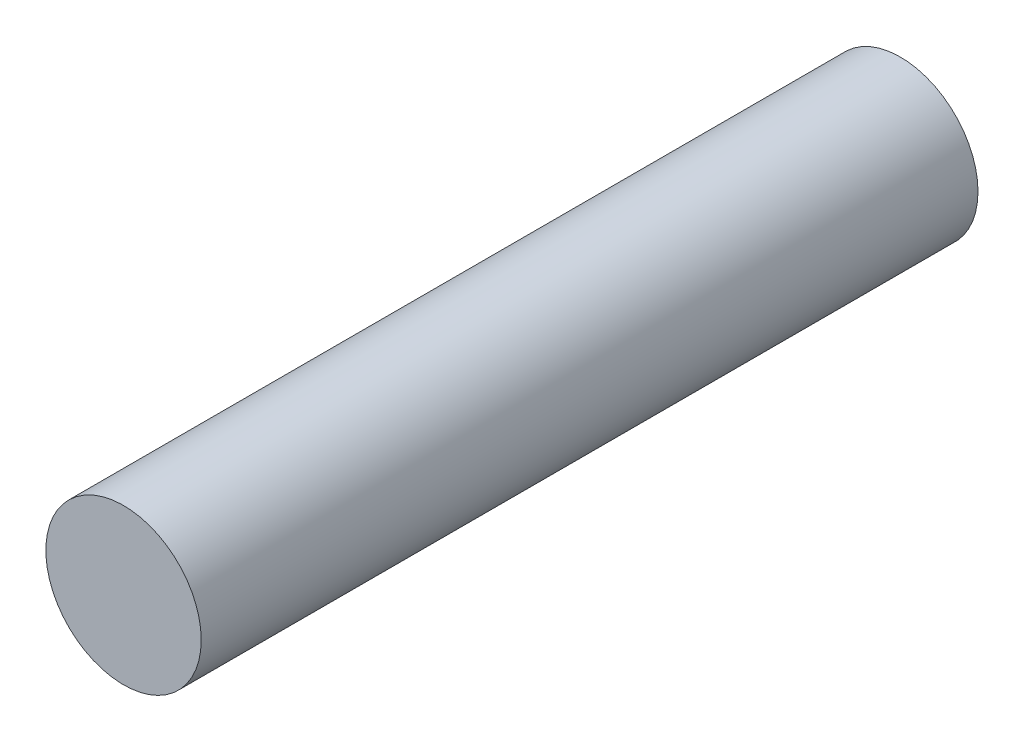
from build123d import *

# Parameters (mm, degrees)
SKETCH_1_R      = 1
EXTRUDE_1_DEPTH = 10


with BuildPart() as part:
    # 草图1 → 凸台-拉伸1 (new body)
    with BuildSketch(Plane.XY):
        Circle(SKETCH_1_R)
    extrude(amount=EXTRUDE_1_DEPTH)


solid = part.part
